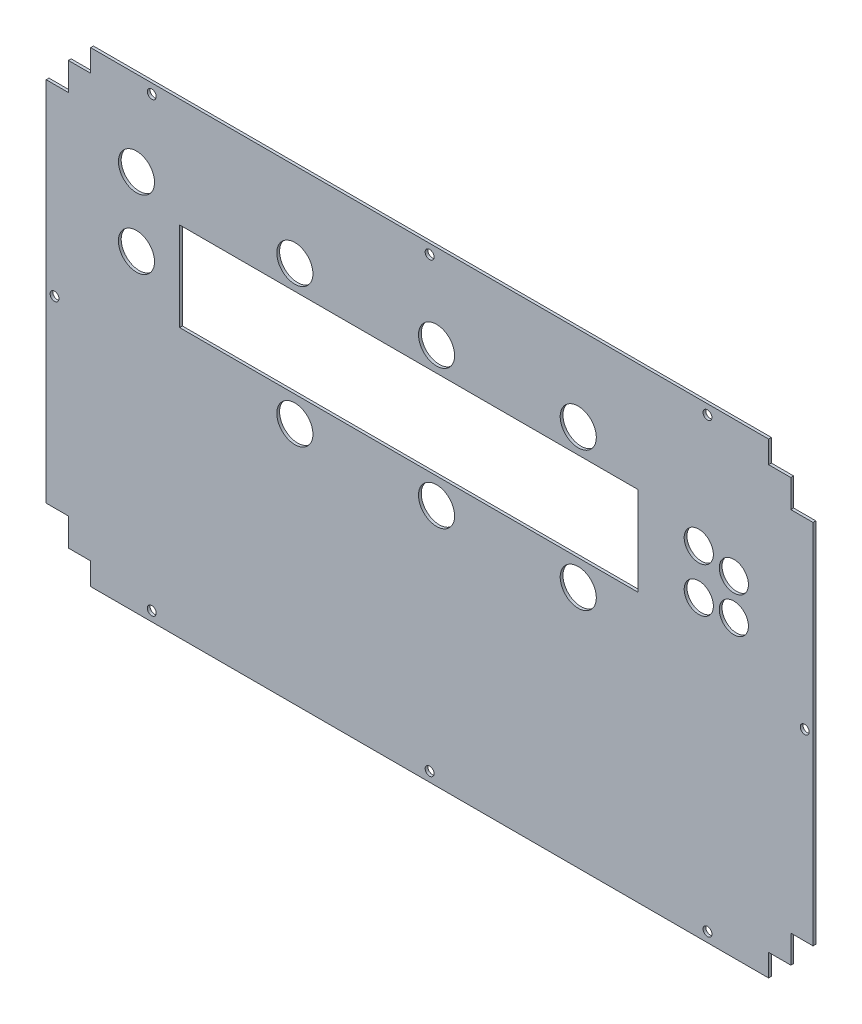
from build123d import *

# Parameters (mm, degrees)
EXTRUDE1_DEPTH        = 1
SKETCH2_W             = 165
SKETCH2_H             = 32
CUT_EXTRUDE1_DEPTH    = 1
SKETCH3_R             = 6.5
SKETCH3_R_2           = 5.25
CUT_EXTRUDE2_DEPTH    = 1
ESBO_O1_R             = 1.6
CORTE_EXTRUS_O1_DEPTH = 2


with BuildPart() as part:
    # Sketch1 → Extrude1 (new body)
    with BuildSketch(Plane.XY):
        Polygon((-122, 84), (122, 84), (122, 76), (130, 76), (130, 66), (138, 66), (138, -66), (130, -66), (130, -76), (122, -76), (122, -84), (-122, -84), (-122, -76), (-130, -76), (-130, -66), (-138, -66), (-138, 66), (-130, 66), (-130, 76), (-122, 76), align=None)
    extrude(amount=EXTRUDE1_DEPTH)

    # Sketch2 → Cut-Extrude1 (cut)
    with BuildSketch(Plane.XY.offset(1)):
        with Locations((-7.5, 28.75)):
            Rectangle(SKETCH2_W, SKETCH2_H)
    extrude(amount=-CUT_EXTRUDE1_DEPTH, mode=Mode.SUBTRACT)

    # Sketch3 → Cut-Extrude2 (cut)
    with BuildSketch(Plane.XY.offset(1)):
        with Locations((-105.5, 53.5)):
            Circle(SKETCH3_R)
        with Locations((-105.5, 28.75)):
            Circle(SKETCH3_R)
        with Locations((-48.5, 3.5)):
            Circle(SKETCH3_R)
        with Locations((2.5, 3.5)):
            Circle(SKETCH3_R)
        with Locations((53.5, 3.5)):
            Circle(SKETCH3_R)
        with Locations((53.5, 53.5)):
            Circle(SKETCH3_R)
        with Locations((2.5, 53.5)):
            Circle(SKETCH3_R)
        with Locations((-48.5, 53.5)):
            Circle(SKETCH3_R)
        with Locations((96.873262634, 38.092814818)):
            Circle(SKETCH3_R_2)
        with Locations((109.5, 35)):
            Circle(SKETCH3_R_2)
        with Locations((109.5, 22)):
            Circle(SKETCH3_R_2)
        with Locations((96.873262634, 22)):
            Circle(SKETCH3_R_2)
    extrude(amount=-CUT_EXTRUDE2_DEPTH, mode=Mode.SUBTRACT)

    # Esboço1 → Corte-extrusão1 (cut, through all)
    with BuildSketch(Plane.XY.offset(1)):
        with Locations((0, -80.5)):
            Circle(ESBO_O1_R)
        with Locations((-100, -80.5)):
            Circle(ESBO_O1_R)
        with Locations((100, -80.5)):
            Circle(ESBO_O1_R)
        with Locations((-135, 0)):
            Circle(ESBO_O1_R)
        with Locations((135, 0)):
            Circle(ESBO_O1_R)
        with Locations((100, 80.5)):
            Circle(ESBO_O1_R)
        with Locations((-100, 80.5)):
            Circle(ESBO_O1_R)
        with Locations((0, 80.5)):
            Circle(ESBO_O1_R)
    extrude(amount=-CORTE_EXTRUS_O1_DEPTH, mode=Mode.SUBTRACT)


solid = part.part
